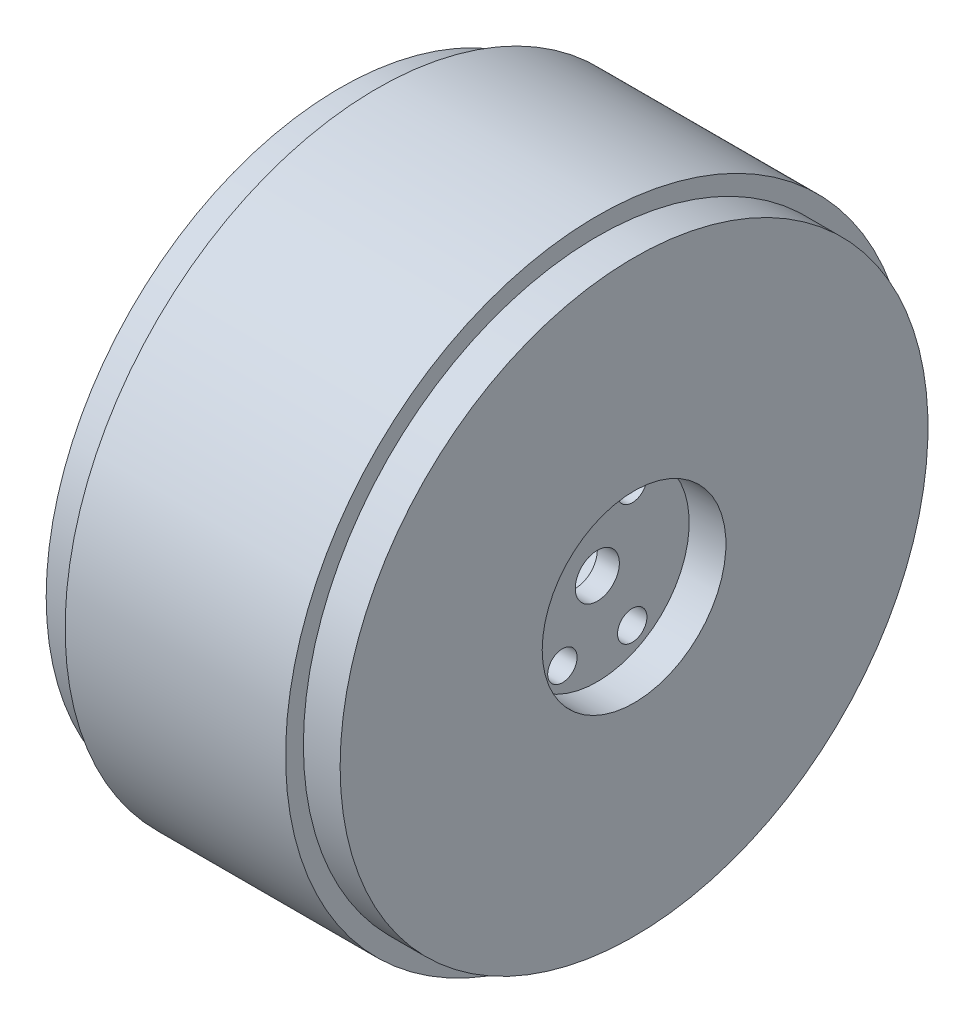
from build123d import *

# Parameters (mm, degrees)
ESQUISSE2_W             = 5
ESQUISSE2_H             = 12.5
ESQUISSE3_R             = 2
ENL_V_MAT_EXTRU_1_DEPTH = 36
ESQUISSE4_R             = 3
ENL_V_MAT_EXTRU_2_DEPTH = 36
ESQUISSE5_W             = 30
ESQUISSE5_H             = 3.421913798


with BuildPart() as part:
    # Esquisse1 → Révolution1 (revolve)
    with BuildSketch(Plane.XY):
        Polygon((0, 34), (0, 0), (8, 0), (8, 40), (3, 40), (3, 39), (-27, 39), (-27, 40), (-32, 40), (-32, 34), align=None)
    revolve(axis=Axis((-49.644499027, 0, 0), (1, 0, 0)))

    # Esquisse2 → Enlèvement de matière-Révolution1 (revolve, cut)
    with BuildSketch(Plane.XY):
        with Locations((5.5, 6.25)):
            Rectangle(ESQUISSE2_W, ESQUISSE2_H)
    revolve(axis=Axis((0, 0, 0), (1, 0, 0)), mode=Mode.SUBTRACT)

    # Esquisse3 → Enlèv. mat.-Extru.1 (cut, through all)
    with BuildSketch(Plane(origin=(3, 0, 0), x_dir=(0, 0, -1), z_dir=(1, 0, 0))):
        with Locations((4.75, 8.227241336)):
            Circle(ESQUISSE3_R)
        with Locations((-4.75, 8.227241336)):
            Circle(ESQUISSE3_R)
        with Locations((4.75, -8.227241336)):
            Circle(ESQUISSE3_R)
        with Locations((-4.75, -8.227241336)):
            Circle(ESQUISSE3_R)
    extrude(amount=-ENL_V_MAT_EXTRU_1_DEPTH, mode=Mode.SUBTRACT)

    # Esquisse4 → Enlèv. mat.-Extru.2 (cut, through all)
    with BuildSketch(Plane(origin=(3, 0, 0), x_dir=(0, 0, -1), z_dir=(1, 0, 0))):
        Circle(ESQUISSE4_R)
    extrude(amount=-ENL_V_MAT_EXTRU_2_DEPTH, mode=Mode.SUBTRACT)

    # Esquisse5 → Révolution2 (revolve)
    with BuildSketch(Plane.XY):
        with Locations((-12, 40.710956899)):
            Rectangle(ESQUISSE5_W, ESQUISSE5_H)
    revolve(axis=Axis((0, 0, 0), (-1, 0, 0)))


solid = part.part
